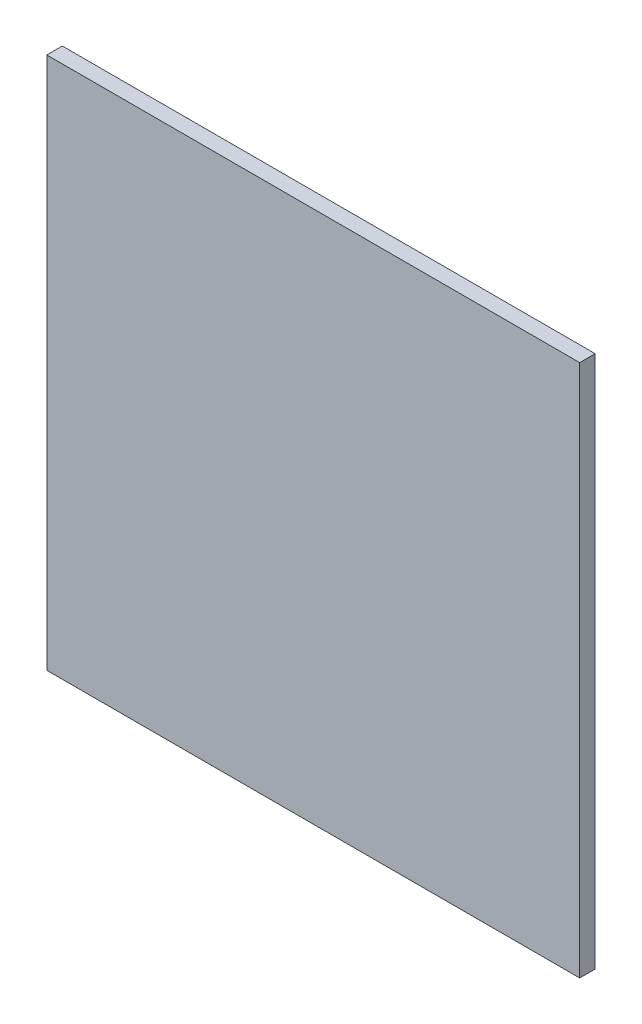
from build123d import *

# Parameters (mm, degrees)
SKETCH1_W           = 86
SKETCH1_H           = 86
BOSS_EXTRUDE1_DEPTH = 2.5


with BuildPart() as part:
    # Sketch1 → Boss-Extrude1 (new body)
    with BuildSketch(Plane.XY):
        with Locations((7.802500728, 15.105981827)):
            Rectangle(SKETCH1_W, SKETCH1_H)
    extrude(amount=BOSS_EXTRUDE1_DEPTH)


solid = part.part
